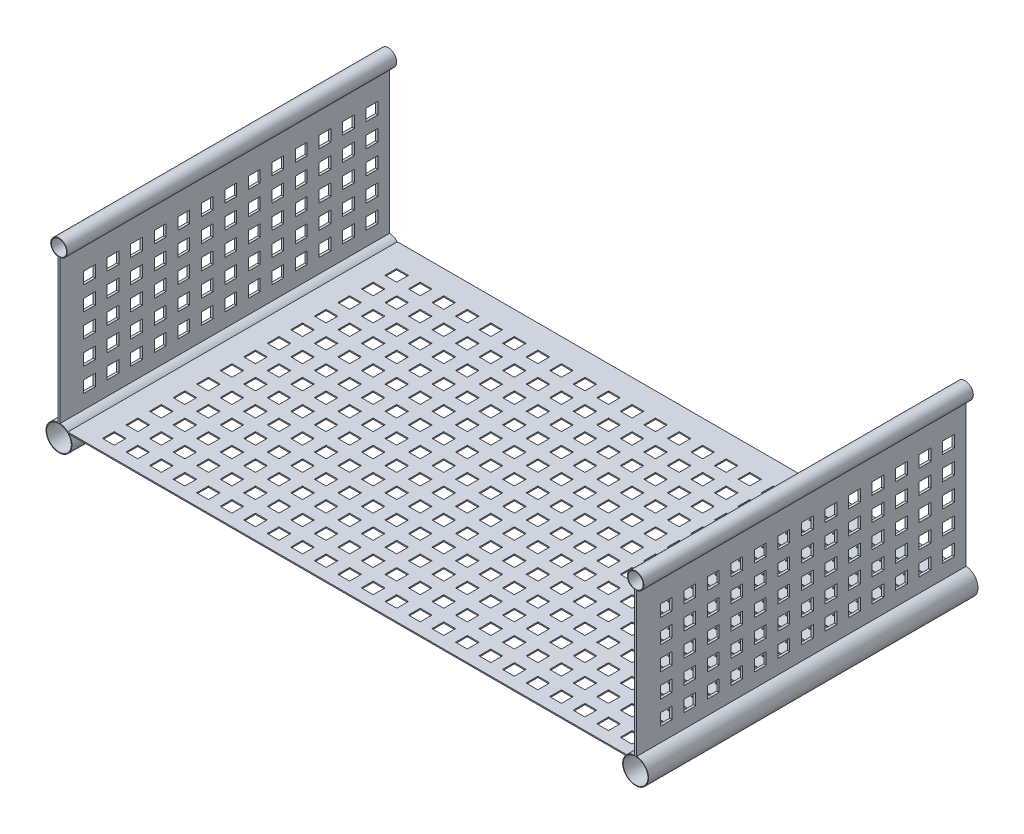
from build123d import *

# Parameters (mm, degrees)
SKETCH1_R               = 10.5
SKETCH1_R_2             = 6.5
BOSS_EXTRUDE1_DEPTH     = 280
SKETCH2_W               = 10
SKETCH2_H               = 10
CUT_EXTRUDE3_DEPTH      = 11
CUT_EXTRUDE3_DEPTH_BACK = 503
SKETCH3_W               = 10
SKETCH3_H               = 10
CUT_EXTRUDE4_DEPTH      = 20


with BuildPart() as part:
    # Sketch1 → Boss-Extrude1 (new body)
    with BuildSketch(Plane.XY):
        with BuildLine():
            Line((7.549834435, 8), (482.450165565, 8))
            ThreePointArc((482.450165565, 8), (485.47704603, 10.027107628), (489, 10.95445115))
            Line((489, 10.95445115), (489, 133.07179677))
            ThreePointArc((489, 133.07179677), (490, 147), (491, 133.07179677))
            Line((491, 133.07179677), (491, 10.95445115))
            ThreePointArc((491, 10.95445115), (494.232821788, -10.152990678), (481.514718626, 7))
            Line((481.514718626, 7), (8.485281374, 7))
            ThreePointArc((8.485281374, 7), (-4.232821788, -10.152990678), (-1, 10.95445115))
            Line((-1, 10.95445115), (-1, 133.07179677))
            ThreePointArc((-1, 133.07179677), (0, 147), (1, 133.07179677))
            Line((1, 133.07179677), (1, 10.95445115))
            ThreePointArc((1, 10.95445115), (4.52295397, 10.027107628), (7.549834435, 8))
        make_face()
        Circle(SKETCH1_R, mode=Mode.SUBTRACT)
        with Locations((490, 0)):
            Circle(SKETCH1_R, mode=Mode.SUBTRACT)
        with Locations((0, 140)):
            Circle(SKETCH1_R_2, mode=Mode.SUBTRACT)
        with Locations((490, 140)):
            Circle(SKETCH1_R_2, mode=Mode.SUBTRACT)
    extrude(amount=BOSS_EXTRUDE1_DEPTH)

    # Sketch2 → Cut-Extrude3 (cut, two sides)
    with BuildSketch(Plane(origin=(491, 0, 0), x_dir=(0, 0, -1), z_dir=(1, 0, 0))) as cut_extrude3_sk:
        with Locations((-255, 108.07179677)):
            Rectangle(SKETCH2_W, SKETCH2_H)
        with Locations((-235, 108.07179677)):
            Rectangle(SKETCH2_W, SKETCH2_H)
        with Locations((-215, 108.07179677)):
            Rectangle(SKETCH2_W, SKETCH2_H)
        with Locations((-195, 108.07179677)):
            Rectangle(SKETCH2_W, SKETCH2_H)
        with Locations((-175, 108.07179677)):
            Rectangle(SKETCH2_W, SKETCH2_H)
        with Locations((-155, 108.07179677)):
            Rectangle(SKETCH2_W, SKETCH2_H)
        with Locations((-135, 108.07179677)):
            Rectangle(SKETCH2_W, SKETCH2_H)
        with Locations((-115, 108.07179677)):
            Rectangle(SKETCH2_W, SKETCH2_H)
        with Locations((-95, 108.07179677)):
            Rectangle(SKETCH2_W, SKETCH2_H)
        with Locations((-75, 108.07179677)):
            Rectangle(SKETCH2_W, SKETCH2_H)
        with Locations((-55, 108.07179677)):
            Rectangle(SKETCH2_W, SKETCH2_H)
        with Locations((-35, 108.07179677)):
            Rectangle(SKETCH2_W, SKETCH2_H)
        with Locations((-15, 108.07179677)):
            Rectangle(SKETCH2_W, SKETCH2_H)
        with Locations((-235, 88.07179677)):
            Rectangle(SKETCH2_W, SKETCH2_H)
        with Locations((-215, 88.07179677)):
            Rectangle(SKETCH2_W, SKETCH2_H)
        with Locations((-195, 88.07179677)):
            Rectangle(SKETCH2_W, SKETCH2_H)
        with Locations((-175, 88.07179677)):
            Rectangle(SKETCH2_W, SKETCH2_H)
        with Locations((-155, 88.07179677)):
            Rectangle(SKETCH2_W, SKETCH2_H)
        with Locations((-135, 88.07179677)):
            Rectangle(SKETCH2_W, SKETCH2_H)
        with Locations((-115, 88.07179677)):
            Rectangle(SKETCH2_W, SKETCH2_H)
        with Locations((-95, 88.07179677)):
            Rectangle(SKETCH2_W, SKETCH2_H)
        with Locations((-75, 88.07179677)):
            Rectangle(SKETCH2_W, SKETCH2_H)
        with Locations((-55, 88.07179677)):
            Rectangle(SKETCH2_W, SKETCH2_H)
        with Locations((-35, 88.07179677)):
            Rectangle(SKETCH2_W, SKETCH2_H)
        with Locations((-15, 88.07179677)):
            Rectangle(SKETCH2_W, SKETCH2_H)
        with Locations((-235, 68.07179677)):
            Rectangle(SKETCH2_W, SKETCH2_H)
        with Locations((-215, 68.07179677)):
            Rectangle(SKETCH2_W, SKETCH2_H)
        with Locations((-195, 68.07179677)):
            Rectangle(SKETCH2_W, SKETCH2_H)
        with Locations((-175, 68.07179677)):
            Rectangle(SKETCH2_W, SKETCH2_H)
        with Locations((-155, 68.07179677)):
            Rectangle(SKETCH2_W, SKETCH2_H)
        with Locations((-135, 68.07179677)):
            Rectangle(SKETCH2_W, SKETCH2_H)
        with Locations((-115, 68.07179677)):
            Rectangle(SKETCH2_W, SKETCH2_H)
        with Locations((-95, 68.07179677)):
            Rectangle(SKETCH2_W, SKETCH2_H)
        with Locations((-75, 68.07179677)):
            Rectangle(SKETCH2_W, SKETCH2_H)
        with Locations((-55, 68.07179677)):
            Rectangle(SKETCH2_W, SKETCH2_H)
        with Locations((-35, 68.07179677)):
            Rectangle(SKETCH2_W, SKETCH2_H)
        with Locations((-15, 68.07179677)):
            Rectangle(SKETCH2_W, SKETCH2_H)
        with Locations((-235, 48.07179677)):
            Rectangle(SKETCH2_W, SKETCH2_H)
        with Locations((-215, 48.07179677)):
            Rectangle(SKETCH2_W, SKETCH2_H)
        with Locations((-195, 48.07179677)):
            Rectangle(SKETCH2_W, SKETCH2_H)
        with Locations((-175, 48.07179677)):
            Rectangle(SKETCH2_W, SKETCH2_H)
        with Locations((-155, 48.07179677)):
            Rectangle(SKETCH2_W, SKETCH2_H)
        with Locations((-135, 48.07179677)):
            Rectangle(SKETCH2_W, SKETCH2_H)
        with Locations((-115, 48.07179677)):
            Rectangle(SKETCH2_W, SKETCH2_H)
        with Locations((-95, 48.07179677)):
            Rectangle(SKETCH2_W, SKETCH2_H)
        with Locations((-75, 48.07179677)):
            Rectangle(SKETCH2_W, SKETCH2_H)
        with Locations((-55, 48.07179677)):
            Rectangle(SKETCH2_W, SKETCH2_H)
        with Locations((-35, 48.07179677)):
            Rectangle(SKETCH2_W, SKETCH2_H)
        with Locations((-15, 48.07179677)):
            Rectangle(SKETCH2_W, SKETCH2_H)
        with Locations((-235, 28.07179677)):
            Rectangle(SKETCH2_W, SKETCH2_H)
        with Locations((-215, 28.07179677)):
            Rectangle(SKETCH2_W, SKETCH2_H)
        with Locations((-195, 28.07179677)):
            Rectangle(SKETCH2_W, SKETCH2_H)
        with Locations((-175, 28.07179677)):
            Rectangle(SKETCH2_W, SKETCH2_H)
        with Locations((-155, 28.07179677)):
            Rectangle(SKETCH2_W, SKETCH2_H)
        with Locations((-135, 28.07179677)):
            Rectangle(SKETCH2_W, SKETCH2_H)
        with Locations((-115, 28.07179677)):
            Rectangle(SKETCH2_W, SKETCH2_H)
        with Locations((-95, 28.07179677)):
            Rectangle(SKETCH2_W, SKETCH2_H)
        with Locations((-75, 28.07179677)):
            Rectangle(SKETCH2_W, SKETCH2_H)
        with Locations((-55, 28.07179677)):
            Rectangle(SKETCH2_W, SKETCH2_H)
        with Locations((-35, 28.07179677)):
            Rectangle(SKETCH2_W, SKETCH2_H)
        with Locations((-15, 28.07179677)):
            Rectangle(SKETCH2_W, SKETCH2_H)
        with Locations((-255, 88.07179677)):
            Rectangle(SKETCH2_W, SKETCH2_H)
        with Locations((-255, 68.07179677)):
            Rectangle(SKETCH2_W, SKETCH2_H)
        with Locations((-255, 48.07179677)):
            Rectangle(SKETCH2_W, SKETCH2_H)
        with Locations((-255, 28.07179677)):
            Rectangle(SKETCH2_W, SKETCH2_H)
    extrude(amount=CUT_EXTRUDE3_DEPTH, mode=Mode.SUBTRACT)
    extrude(cut_extrude3_sk.sketch, amount=-CUT_EXTRUDE3_DEPTH_BACK, mode=Mode.SUBTRACT)

    # Sketch3 → Cut-Extrude4 (cut, through all)
    with BuildSketch(Plane(origin=(0, 8, 0), x_dir=(1, 0, 0), z_dir=(0, 1, 0))):
        with Locations((32, -25)):
            Rectangle(SKETCH3_W, SKETCH3_H)
        with Locations((52, -25)):
            Rectangle(SKETCH3_W, SKETCH3_H)
        with Locations((72, -25)):
            Rectangle(SKETCH3_W, SKETCH3_H)
        with Locations((92, -25)):
            Rectangle(SKETCH3_W, SKETCH3_H)
        with Locations((112, -25)):
            Rectangle(SKETCH3_W, SKETCH3_H)
        with Locations((132, -25)):
            Rectangle(SKETCH3_W, SKETCH3_H)
        with Locations((152, -25)):
            Rectangle(SKETCH3_W, SKETCH3_H)
        with Locations((172, -25)):
            Rectangle(SKETCH3_W, SKETCH3_H)
        with Locations((192, -25)):
            Rectangle(SKETCH3_W, SKETCH3_H)
        with Locations((212, -25)):
            Rectangle(SKETCH3_W, SKETCH3_H)
        with Locations((232, -25)):
            Rectangle(SKETCH3_W, SKETCH3_H)
        with Locations((252, -25)):
            Rectangle(SKETCH3_W, SKETCH3_H)
        with Locations((272, -25)):
            Rectangle(SKETCH3_W, SKETCH3_H)
        with Locations((292, -25)):
            Rectangle(SKETCH3_W, SKETCH3_H)
        with Locations((312, -25)):
            Rectangle(SKETCH3_W, SKETCH3_H)
        with Locations((332, -25)):
            Rectangle(SKETCH3_W, SKETCH3_H)
        with Locations((352, -25)):
            Rectangle(SKETCH3_W, SKETCH3_H)
        with Locations((372, -25)):
            Rectangle(SKETCH3_W, SKETCH3_H)
        with Locations((392, -25)):
            Rectangle(SKETCH3_W, SKETCH3_H)
        with Locations((412, -25)):
            Rectangle(SKETCH3_W, SKETCH3_H)
        with Locations((432, -25)):
            Rectangle(SKETCH3_W, SKETCH3_H)
        with Locations((452, -25)):
            Rectangle(SKETCH3_W, SKETCH3_H)
        with Locations((472, -25)):
            Rectangle(SKETCH3_W, SKETCH3_H)
        with Locations((52, -45)):
            Rectangle(SKETCH3_W, SKETCH3_H)
        with Locations((72, -45)):
            Rectangle(SKETCH3_W, SKETCH3_H)
        with Locations((92, -45)):
            Rectangle(SKETCH3_W, SKETCH3_H)
        with Locations((112, -45)):
            Rectangle(SKETCH3_W, SKETCH3_H)
        with Locations((132, -45)):
            Rectangle(SKETCH3_W, SKETCH3_H)
        with Locations((152, -45)):
            Rectangle(SKETCH3_W, SKETCH3_H)
        with Locations((172, -45)):
            Rectangle(SKETCH3_W, SKETCH3_H)
        with Locations((192, -45)):
            Rectangle(SKETCH3_W, SKETCH3_H)
        with Locations((212, -45)):
            Rectangle(SKETCH3_W, SKETCH3_H)
        with Locations((232, -45)):
            Rectangle(SKETCH3_W, SKETCH3_H)
        with Locations((252, -45)):
            Rectangle(SKETCH3_W, SKETCH3_H)
        with Locations((272, -45)):
            Rectangle(SKETCH3_W, SKETCH3_H)
        with Locations((292, -45)):
            Rectangle(SKETCH3_W, SKETCH3_H)
        with Locations((312, -45)):
            Rectangle(SKETCH3_W, SKETCH3_H)
        with Locations((332, -45)):
            Rectangle(SKETCH3_W, SKETCH3_H)
        with Locations((352, -45)):
            Rectangle(SKETCH3_W, SKETCH3_H)
        with Locations((372, -45)):
            Rectangle(SKETCH3_W, SKETCH3_H)
        with Locations((392, -45)):
            Rectangle(SKETCH3_W, SKETCH3_H)
        with Locations((412, -45)):
            Rectangle(SKETCH3_W, SKETCH3_H)
        with Locations((432, -45)):
            Rectangle(SKETCH3_W, SKETCH3_H)
        with Locations((452, -45)):
            Rectangle(SKETCH3_W, SKETCH3_H)
        with Locations((472, -45)):
            Rectangle(SKETCH3_W, SKETCH3_H)
        with Locations((52, -65)):
            Rectangle(SKETCH3_W, SKETCH3_H)
        with Locations((72, -65)):
            Rectangle(SKETCH3_W, SKETCH3_H)
        with Locations((92, -65)):
            Rectangle(SKETCH3_W, SKETCH3_H)
        with Locations((112, -65)):
            Rectangle(SKETCH3_W, SKETCH3_H)
        with Locations((132, -65)):
            Rectangle(SKETCH3_W, SKETCH3_H)
        with Locations((152, -65)):
            Rectangle(SKETCH3_W, SKETCH3_H)
        with Locations((172, -65)):
            Rectangle(SKETCH3_W, SKETCH3_H)
        with Locations((192, -65)):
            Rectangle(SKETCH3_W, SKETCH3_H)
        with Locations((212, -65)):
            Rectangle(SKETCH3_W, SKETCH3_H)
        with Locations((232, -65)):
            Rectangle(SKETCH3_W, SKETCH3_H)
        with Locations((252, -65)):
            Rectangle(SKETCH3_W, SKETCH3_H)
        with Locations((272, -65)):
            Rectangle(SKETCH3_W, SKETCH3_H)
        with Locations((292, -65)):
            Rectangle(SKETCH3_W, SKETCH3_H)
        with Locations((312, -65)):
            Rectangle(SKETCH3_W, SKETCH3_H)
        with Locations((332, -65)):
            Rectangle(SKETCH3_W, SKETCH3_H)
        with Locations((352, -65)):
            Rectangle(SKETCH3_W, SKETCH3_H)
        with Locations((372, -65)):
            Rectangle(SKETCH3_W, SKETCH3_H)
        with Locations((392, -65)):
            Rectangle(SKETCH3_W, SKETCH3_H)
        with Locations((412, -65)):
            Rectangle(SKETCH3_W, SKETCH3_H)
        with Locations((432, -65)):
            Rectangle(SKETCH3_W, SKETCH3_H)
        with Locations((452, -65)):
            Rectangle(SKETCH3_W, SKETCH3_H)
        with Locations((472, -65)):
            Rectangle(SKETCH3_W, SKETCH3_H)
        with Locations((52, -85)):
            Rectangle(SKETCH3_W, SKETCH3_H)
        with Locations((72, -85)):
            Rectangle(SKETCH3_W, SKETCH3_H)
        with Locations((92, -85)):
            Rectangle(SKETCH3_W, SKETCH3_H)
        with Locations((112, -85)):
            Rectangle(SKETCH3_W, SKETCH3_H)
        with Locations((132, -85)):
            Rectangle(SKETCH3_W, SKETCH3_H)
        with Locations((152, -85)):
            Rectangle(SKETCH3_W, SKETCH3_H)
        with Locations((172, -85)):
            Rectangle(SKETCH3_W, SKETCH3_H)
        with Locations((192, -85)):
            Rectangle(SKETCH3_W, SKETCH3_H)
        with Locations((212, -85)):
            Rectangle(SKETCH3_W, SKETCH3_H)
        with Locations((232, -85)):
            Rectangle(SKETCH3_W, SKETCH3_H)
        with Locations((252, -85)):
            Rectangle(SKETCH3_W, SKETCH3_H)
        with Locations((272, -85)):
            Rectangle(SKETCH3_W, SKETCH3_H)
        with Locations((292, -85)):
            Rectangle(SKETCH3_W, SKETCH3_H)
        with Locations((312, -85)):
            Rectangle(SKETCH3_W, SKETCH3_H)
        with Locations((332, -85)):
            Rectangle(SKETCH3_W, SKETCH3_H)
        with Locations((352, -85)):
            Rectangle(SKETCH3_W, SKETCH3_H)
        with Locations((372, -85)):
            Rectangle(SKETCH3_W, SKETCH3_H)
        with Locations((392, -85)):
            Rectangle(SKETCH3_W, SKETCH3_H)
        with Locations((412, -85)):
            Rectangle(SKETCH3_W, SKETCH3_H)
        with Locations((432, -85)):
            Rectangle(SKETCH3_W, SKETCH3_H)
        with Locations((452, -85)):
            Rectangle(SKETCH3_W, SKETCH3_H)
        with Locations((472, -85)):
            Rectangle(SKETCH3_W, SKETCH3_H)
        with Locations((52, -105)):
            Rectangle(SKETCH3_W, SKETCH3_H)
        with Locations((72, -105)):
            Rectangle(SKETCH3_W, SKETCH3_H)
        with Locations((92, -105)):
            Rectangle(SKETCH3_W, SKETCH3_H)
        with Locations((112, -105)):
            Rectangle(SKETCH3_W, SKETCH3_H)
        with Locations((132, -105)):
            Rectangle(SKETCH3_W, SKETCH3_H)
        with Locations((152, -105)):
            Rectangle(SKETCH3_W, SKETCH3_H)
        with Locations((172, -105)):
            Rectangle(SKETCH3_W, SKETCH3_H)
        with Locations((192, -105)):
            Rectangle(SKETCH3_W, SKETCH3_H)
        with Locations((212, -105)):
            Rectangle(SKETCH3_W, SKETCH3_H)
        with Locations((232, -105)):
            Rectangle(SKETCH3_W, SKETCH3_H)
        with Locations((252, -105)):
            Rectangle(SKETCH3_W, SKETCH3_H)
        with Locations((272, -105)):
            Rectangle(SKETCH3_W, SKETCH3_H)
        with Locations((292, -105)):
            Rectangle(SKETCH3_W, SKETCH3_H)
        with Locations((312, -105)):
            Rectangle(SKETCH3_W, SKETCH3_H)
        with Locations((332, -105)):
            Rectangle(SKETCH3_W, SKETCH3_H)
        with Locations((352, -105)):
            Rectangle(SKETCH3_W, SKETCH3_H)
        with Locations((372, -105)):
            Rectangle(SKETCH3_W, SKETCH3_H)
        with Locations((392, -105)):
            Rectangle(SKETCH3_W, SKETCH3_H)
        with Locations((412, -105)):
            Rectangle(SKETCH3_W, SKETCH3_H)
        with Locations((432, -105)):
            Rectangle(SKETCH3_W, SKETCH3_H)
        with Locations((452, -105)):
            Rectangle(SKETCH3_W, SKETCH3_H)
        with Locations((472, -105)):
            Rectangle(SKETCH3_W, SKETCH3_H)
        with Locations((52, -125)):
            Rectangle(SKETCH3_W, SKETCH3_H)
        with Locations((72, -125)):
            Rectangle(SKETCH3_W, SKETCH3_H)
        with Locations((92, -125)):
            Rectangle(SKETCH3_W, SKETCH3_H)
        with Locations((112, -125)):
            Rectangle(SKETCH3_W, SKETCH3_H)
        with Locations((132, -125)):
            Rectangle(SKETCH3_W, SKETCH3_H)
        with Locations((152, -125)):
            Rectangle(SKETCH3_W, SKETCH3_H)
        with Locations((172, -125)):
            Rectangle(SKETCH3_W, SKETCH3_H)
        with Locations((192, -125)):
            Rectangle(SKETCH3_W, SKETCH3_H)
        with Locations((212, -125)):
            Rectangle(SKETCH3_W, SKETCH3_H)
        with Locations((232, -125)):
            Rectangle(SKETCH3_W, SKETCH3_H)
        with Locations((252, -125)):
            Rectangle(SKETCH3_W, SKETCH3_H)
        with Locations((272, -125)):
            Rectangle(SKETCH3_W, SKETCH3_H)
        with Locations((292, -125)):
            Rectangle(SKETCH3_W, SKETCH3_H)
        with Locations((312, -125)):
            Rectangle(SKETCH3_W, SKETCH3_H)
        with Locations((332, -125)):
            Rectangle(SKETCH3_W, SKETCH3_H)
        with Locations((352, -125)):
            Rectangle(SKETCH3_W, SKETCH3_H)
        with Locations((372, -125)):
            Rectangle(SKETCH3_W, SKETCH3_H)
        with Locations((392, -125)):
            Rectangle(SKETCH3_W, SKETCH3_H)
        with Locations((412, -125)):
            Rectangle(SKETCH3_W, SKETCH3_H)
        with Locations((432, -125)):
            Rectangle(SKETCH3_W, SKETCH3_H)
        with Locations((452, -125)):
            Rectangle(SKETCH3_W, SKETCH3_H)
        with Locations((472, -125)):
            Rectangle(SKETCH3_W, SKETCH3_H)
        with Locations((52, -145)):
            Rectangle(SKETCH3_W, SKETCH3_H)
        with Locations((72, -145)):
            Rectangle(SKETCH3_W, SKETCH3_H)
        with Locations((92, -145)):
            Rectangle(SKETCH3_W, SKETCH3_H)
        with Locations((112, -145)):
            Rectangle(SKETCH3_W, SKETCH3_H)
        with Locations((132, -145)):
            Rectangle(SKETCH3_W, SKETCH3_H)
        with Locations((152, -145)):
            Rectangle(SKETCH3_W, SKETCH3_H)
        with Locations((172, -145)):
            Rectangle(SKETCH3_W, SKETCH3_H)
        with Locations((192, -145)):
            Rectangle(SKETCH3_W, SKETCH3_H)
        with Locations((212, -145)):
            Rectangle(SKETCH3_W, SKETCH3_H)
        with Locations((232, -145)):
            Rectangle(SKETCH3_W, SKETCH3_H)
        with Locations((252, -145)):
            Rectangle(SKETCH3_W, SKETCH3_H)
        with Locations((272, -145)):
            Rectangle(SKETCH3_W, SKETCH3_H)
        with Locations((292, -145)):
            Rectangle(SKETCH3_W, SKETCH3_H)
        with Locations((312, -145)):
            Rectangle(SKETCH3_W, SKETCH3_H)
        with Locations((332, -145)):
            Rectangle(SKETCH3_W, SKETCH3_H)
        with Locations((352, -145)):
            Rectangle(SKETCH3_W, SKETCH3_H)
        with Locations((372, -145)):
            Rectangle(SKETCH3_W, SKETCH3_H)
        with Locations((392, -145)):
            Rectangle(SKETCH3_W, SKETCH3_H)
        with Locations((412, -145)):
            Rectangle(SKETCH3_W, SKETCH3_H)
        with Locations((432, -145)):
            Rectangle(SKETCH3_W, SKETCH3_H)
        with Locations((452, -145)):
            Rectangle(SKETCH3_W, SKETCH3_H)
        with Locations((472, -145)):
            Rectangle(SKETCH3_W, SKETCH3_H)
        with Locations((52, -165)):
            Rectangle(SKETCH3_W, SKETCH3_H)
        with Locations((72, -165)):
            Rectangle(SKETCH3_W, SKETCH3_H)
        with Locations((92, -165)):
            Rectangle(SKETCH3_W, SKETCH3_H)
        with Locations((112, -165)):
            Rectangle(SKETCH3_W, SKETCH3_H)
        with Locations((132, -165)):
            Rectangle(SKETCH3_W, SKETCH3_H)
        with Locations((152, -165)):
            Rectangle(SKETCH3_W, SKETCH3_H)
        with Locations((172, -165)):
            Rectangle(SKETCH3_W, SKETCH3_H)
        with Locations((192, -165)):
            Rectangle(SKETCH3_W, SKETCH3_H)
        with Locations((212, -165)):
            Rectangle(SKETCH3_W, SKETCH3_H)
        with Locations((232, -165)):
            Rectangle(SKETCH3_W, SKETCH3_H)
        with Locations((252, -165)):
            Rectangle(SKETCH3_W, SKETCH3_H)
        with Locations((272, -165)):
            Rectangle(SKETCH3_W, SKETCH3_H)
        with Locations((292, -165)):
            Rectangle(SKETCH3_W, SKETCH3_H)
        with Locations((312, -165)):
            Rectangle(SKETCH3_W, SKETCH3_H)
        with Locations((332, -165)):
            Rectangle(SKETCH3_W, SKETCH3_H)
        with Locations((352, -165)):
            Rectangle(SKETCH3_W, SKETCH3_H)
        with Locations((372, -165)):
            Rectangle(SKETCH3_W, SKETCH3_H)
        with Locations((392, -165)):
            Rectangle(SKETCH3_W, SKETCH3_H)
        with Locations((412, -165)):
            Rectangle(SKETCH3_W, SKETCH3_H)
        with Locations((432, -165)):
            Rectangle(SKETCH3_W, SKETCH3_H)
        with Locations((452, -165)):
            Rectangle(SKETCH3_W, SKETCH3_H)
        with Locations((472, -165)):
            Rectangle(SKETCH3_W, SKETCH3_H)
        with Locations((52, -185)):
            Rectangle(SKETCH3_W, SKETCH3_H)
        with Locations((72, -185)):
            Rectangle(SKETCH3_W, SKETCH3_H)
        with Locations((92, -185)):
            Rectangle(SKETCH3_W, SKETCH3_H)
        with Locations((112, -185)):
            Rectangle(SKETCH3_W, SKETCH3_H)
        with Locations((132, -185)):
            Rectangle(SKETCH3_W, SKETCH3_H)
        with Locations((152, -185)):
            Rectangle(SKETCH3_W, SKETCH3_H)
        with Locations((172, -185)):
            Rectangle(SKETCH3_W, SKETCH3_H)
        with Locations((192, -185)):
            Rectangle(SKETCH3_W, SKETCH3_H)
        with Locations((212, -185)):
            Rectangle(SKETCH3_W, SKETCH3_H)
        with Locations((232, -185)):
            Rectangle(SKETCH3_W, SKETCH3_H)
        with Locations((252, -185)):
            Rectangle(SKETCH3_W, SKETCH3_H)
        with Locations((272, -185)):
            Rectangle(SKETCH3_W, SKETCH3_H)
        with Locations((292, -185)):
            Rectangle(SKETCH3_W, SKETCH3_H)
        with Locations((312, -185)):
            Rectangle(SKETCH3_W, SKETCH3_H)
        with Locations((332, -185)):
            Rectangle(SKETCH3_W, SKETCH3_H)
        with Locations((352, -185)):
            Rectangle(SKETCH3_W, SKETCH3_H)
        with Locations((372, -185)):
            Rectangle(SKETCH3_W, SKETCH3_H)
        with Locations((392, -185)):
            Rectangle(SKETCH3_W, SKETCH3_H)
        with Locations((412, -185)):
            Rectangle(SKETCH3_W, SKETCH3_H)
        with Locations((432, -185)):
            Rectangle(SKETCH3_W, SKETCH3_H)
        with Locations((452, -185)):
            Rectangle(SKETCH3_W, SKETCH3_H)
        with Locations((472, -185)):
            Rectangle(SKETCH3_W, SKETCH3_H)
        with Locations((52, -205)):
            Rectangle(SKETCH3_W, SKETCH3_H)
        with Locations((72, -205)):
            Rectangle(SKETCH3_W, SKETCH3_H)
        with Locations((92, -205)):
            Rectangle(SKETCH3_W, SKETCH3_H)
        with Locations((112, -205)):
            Rectangle(SKETCH3_W, SKETCH3_H)
        with Locations((132, -205)):
            Rectangle(SKETCH3_W, SKETCH3_H)
        with Locations((152, -205)):
            Rectangle(SKETCH3_W, SKETCH3_H)
        with Locations((172, -205)):
            Rectangle(SKETCH3_W, SKETCH3_H)
        with Locations((192, -205)):
            Rectangle(SKETCH3_W, SKETCH3_H)
        with Locations((212, -205)):
            Rectangle(SKETCH3_W, SKETCH3_H)
        with Locations((232, -205)):
            Rectangle(SKETCH3_W, SKETCH3_H)
        with Locations((252, -205)):
            Rectangle(SKETCH3_W, SKETCH3_H)
        with Locations((272, -205)):
            Rectangle(SKETCH3_W, SKETCH3_H)
        with Locations((292, -205)):
            Rectangle(SKETCH3_W, SKETCH3_H)
        with Locations((312, -205)):
            Rectangle(SKETCH3_W, SKETCH3_H)
        with Locations((332, -205)):
            Rectangle(SKETCH3_W, SKETCH3_H)
        with Locations((352, -205)):
            Rectangle(SKETCH3_W, SKETCH3_H)
        with Locations((372, -205)):
            Rectangle(SKETCH3_W, SKETCH3_H)
        with Locations((392, -205)):
            Rectangle(SKETCH3_W, SKETCH3_H)
        with Locations((412, -205)):
            Rectangle(SKETCH3_W, SKETCH3_H)
        with Locations((432, -205)):
            Rectangle(SKETCH3_W, SKETCH3_H)
        with Locations((452, -205)):
            Rectangle(SKETCH3_W, SKETCH3_H)
        with Locations((472, -205)):
            Rectangle(SKETCH3_W, SKETCH3_H)
        with Locations((52, -225)):
            Rectangle(SKETCH3_W, SKETCH3_H)
        with Locations((72, -225)):
            Rectangle(SKETCH3_W, SKETCH3_H)
        with Locations((92, -225)):
            Rectangle(SKETCH3_W, SKETCH3_H)
        with Locations((112, -225)):
            Rectangle(SKETCH3_W, SKETCH3_H)
        with Locations((132, -225)):
            Rectangle(SKETCH3_W, SKETCH3_H)
        with Locations((152, -225)):
            Rectangle(SKETCH3_W, SKETCH3_H)
        with Locations((172, -225)):
            Rectangle(SKETCH3_W, SKETCH3_H)
        with Locations((192, -225)):
            Rectangle(SKETCH3_W, SKETCH3_H)
        with Locations((212, -225)):
            Rectangle(SKETCH3_W, SKETCH3_H)
        with Locations((232, -225)):
            Rectangle(SKETCH3_W, SKETCH3_H)
        with Locations((252, -225)):
            Rectangle(SKETCH3_W, SKETCH3_H)
        with Locations((272, -225)):
            Rectangle(SKETCH3_W, SKETCH3_H)
        with Locations((292, -225)):
            Rectangle(SKETCH3_W, SKETCH3_H)
        with Locations((312, -225)):
            Rectangle(SKETCH3_W, SKETCH3_H)
        with Locations((332, -225)):
            Rectangle(SKETCH3_W, SKETCH3_H)
        with Locations((352, -225)):
            Rectangle(SKETCH3_W, SKETCH3_H)
        with Locations((372, -225)):
            Rectangle(SKETCH3_W, SKETCH3_H)
        with Locations((392, -225)):
            Rectangle(SKETCH3_W, SKETCH3_H)
        with Locations((412, -225)):
            Rectangle(SKETCH3_W, SKETCH3_H)
        with Locations((432, -225)):
            Rectangle(SKETCH3_W, SKETCH3_H)
        with Locations((452, -225)):
            Rectangle(SKETCH3_W, SKETCH3_H)
        with Locations((472, -225)):
            Rectangle(SKETCH3_W, SKETCH3_H)
        with Locations((52, -245)):
            Rectangle(SKETCH3_W, SKETCH3_H)
        with Locations((72, -245)):
            Rectangle(SKETCH3_W, SKETCH3_H)
        with Locations((92, -245)):
            Rectangle(SKETCH3_W, SKETCH3_H)
        with Locations((112, -245)):
            Rectangle(SKETCH3_W, SKETCH3_H)
        with Locations((132, -245)):
            Rectangle(SKETCH3_W, SKETCH3_H)
        with Locations((152, -245)):
            Rectangle(SKETCH3_W, SKETCH3_H)
        with Locations((172, -245)):
            Rectangle(SKETCH3_W, SKETCH3_H)
        with Locations((192, -245)):
            Rectangle(SKETCH3_W, SKETCH3_H)
        with Locations((212, -245)):
            Rectangle(SKETCH3_W, SKETCH3_H)
        with Locations((232, -245)):
            Rectangle(SKETCH3_W, SKETCH3_H)
        with Locations((252, -245)):
            Rectangle(SKETCH3_W, SKETCH3_H)
        with Locations((272, -245)):
            Rectangle(SKETCH3_W, SKETCH3_H)
        with Locations((292, -245)):
            Rectangle(SKETCH3_W, SKETCH3_H)
        with Locations((312, -245)):
            Rectangle(SKETCH3_W, SKETCH3_H)
        with Locations((332, -245)):
            Rectangle(SKETCH3_W, SKETCH3_H)
        with Locations((352, -245)):
            Rectangle(SKETCH3_W, SKETCH3_H)
        with Locations((372, -245)):
            Rectangle(SKETCH3_W, SKETCH3_H)
        with Locations((392, -245)):
            Rectangle(SKETCH3_W, SKETCH3_H)
        with Locations((412, -245)):
            Rectangle(SKETCH3_W, SKETCH3_H)
        with Locations((432, -245)):
            Rectangle(SKETCH3_W, SKETCH3_H)
        with Locations((452, -245)):
            Rectangle(SKETCH3_W, SKETCH3_H)
        with Locations((472, -245)):
            Rectangle(SKETCH3_W, SKETCH3_H)
        with Locations((52, -265)):
            Rectangle(SKETCH3_W, SKETCH3_H)
        with Locations((72, -265)):
            Rectangle(SKETCH3_W, SKETCH3_H)
        with Locations((92, -265)):
            Rectangle(SKETCH3_W, SKETCH3_H)
        with Locations((112, -265)):
            Rectangle(SKETCH3_W, SKETCH3_H)
        with Locations((132, -265)):
            Rectangle(SKETCH3_W, SKETCH3_H)
        with Locations((152, -265)):
            Rectangle(SKETCH3_W, SKETCH3_H)
        with Locations((172, -265)):
            Rectangle(SKETCH3_W, SKETCH3_H)
        with Locations((192, -265)):
            Rectangle(SKETCH3_W, SKETCH3_H)
        with Locations((212, -265)):
            Rectangle(SKETCH3_W, SKETCH3_H)
        with Locations((232, -265)):
            Rectangle(SKETCH3_W, SKETCH3_H)
        with Locations((252, -265)):
            Rectangle(SKETCH3_W, SKETCH3_H)
        with Locations((272, -265)):
            Rectangle(SKETCH3_W, SKETCH3_H)
        with Locations((292, -265)):
            Rectangle(SKETCH3_W, SKETCH3_H)
        with Locations((312, -265)):
            Rectangle(SKETCH3_W, SKETCH3_H)
        with Locations((332, -265)):
            Rectangle(SKETCH3_W, SKETCH3_H)
        with Locations((352, -265)):
            Rectangle(SKETCH3_W, SKETCH3_H)
        with Locations((372, -265)):
            Rectangle(SKETCH3_W, SKETCH3_H)
        with Locations((392, -265)):
            Rectangle(SKETCH3_W, SKETCH3_H)
        with Locations((412, -265)):
            Rectangle(SKETCH3_W, SKETCH3_H)
        with Locations((432, -265)):
            Rectangle(SKETCH3_W, SKETCH3_H)
        with Locations((452, -265)):
            Rectangle(SKETCH3_W, SKETCH3_H)
        with Locations((472, -265)):
            Rectangle(SKETCH3_W, SKETCH3_H)
        with Locations((32, -45)):
            Rectangle(SKETCH3_W, SKETCH3_H)
        with Locations((32, -65)):
            Rectangle(SKETCH3_W, SKETCH3_H)
        with Locations((32, -85)):
            Rectangle(SKETCH3_W, SKETCH3_H)
        with Locations((32, -105)):
            Rectangle(SKETCH3_W, SKETCH3_H)
        with Locations((32, -125)):
            Rectangle(SKETCH3_W, SKETCH3_H)
        with Locations((32, -145)):
            Rectangle(SKETCH3_W, SKETCH3_H)
        with Locations((32, -165)):
            Rectangle(SKETCH3_W, SKETCH3_H)
        with Locations((32, -185)):
            Rectangle(SKETCH3_W, SKETCH3_H)
        with Locations((32, -205)):
            Rectangle(SKETCH3_W, SKETCH3_H)
        with Locations((32, -225)):
            Rectangle(SKETCH3_W, SKETCH3_H)
        with Locations((32, -245)):
            Rectangle(SKETCH3_W, SKETCH3_H)
        with Locations((32, -265)):
            Rectangle(SKETCH3_W, SKETCH3_H)
    extrude(amount=-CUT_EXTRUDE4_DEPTH, mode=Mode.SUBTRACT)


solid = part.part
